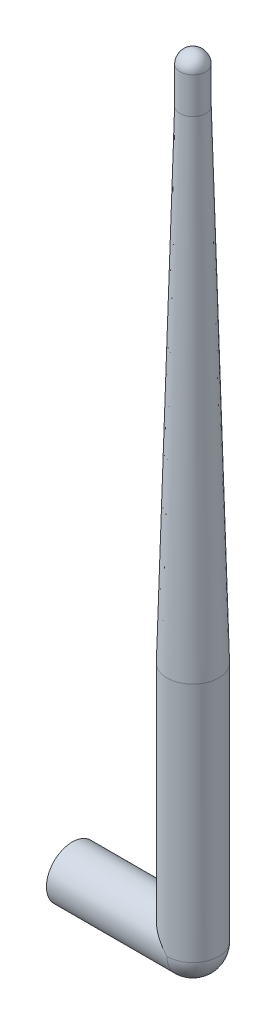
from build123d import *

# Parameters (mm, degrees)
SKETCH1_R           = 5.461
BOSS_EXTRUDE1_DEPTH = 25.4
SKETCH2_R           = 4.191
CUT_EXTRUDE1_DEPTH  = 7.62
SKETCH3_R           = 5.461
BOSS_EXTRUDE2_DEPTH = 50.8
REVOLVE2_ANGLE      = 90
SKETCH8_R           = 2.7305
SKETCH9_R           = 2.7305
BOSS_EXTRUDE3_DEPTH = 7.62
REVOLVE3_ANGLE      = 180


with BuildPart() as part:
    # Sketch1 → Boss-Extrude1 (new body)
    with BuildSketch(Plane(origin=(0, 0, 0), x_dir=(0, 0, -1), z_dir=(1, 0, 0))):
        Circle(SKETCH1_R)
    extrude(amount=BOSS_EXTRUDE1_DEPTH)

    # Sketch2 → Cut-Extrude1 (cut)
    with BuildSketch(Plane.ZY):
        Circle(SKETCH2_R)
    extrude(amount=-CUT_EXTRUDE1_DEPTH, mode=Mode.SUBTRACT)

    # Sketch3 → Boss-Extrude2 (add)
    with BuildSketch(Plane(origin=(0, 0, 0), x_dir=(1, 0, 0), z_dir=(0, 1, 0))):
        with Locations((25.4, 0)):
            Circle(SKETCH3_R)
    extrude(amount=BOSS_EXTRUDE2_DEPTH)

    # Sketch7 → Revolve2 (revolve)
    with BuildSketch(Plane(origin=(25.4, 0, 0), x_dir=(0, 0, -1), z_dir=(1, 0, 0))):
        with BuildLine():
            Line((5.461, 0), (-5.461, 0))
            ThreePointArc((-5.461, 0), (0, -5.461), (5.461, 0))
        make_face()
    revolve(axis=Axis((25.4, 0, -5.461), (0, 0, 1)), revolution_arc=REVOLVE2_ANGLE)

    # Sketch8 → section 1 of loft2
    with BuildSketch(Plane(origin=(0, 152.4, 0), x_dir=(1, 0, 0), z_dir=(0, 1, 0)), mode=Mode.PRIVATE) as loft2_s1:
        with Locations((25.4, 0)):
            Circle(SKETCH8_R)
    # loft from a face of the part (loft2)
    loft([part.faces().sort_by_distance((25.4, 50.8, 0))[0], loft2_s1.sketch])

    # Sketch9 → Boss-Extrude3 (add)
    with BuildSketch(Plane(origin=(0, 152.4, 0), x_dir=(1, 0, 0), z_dir=(0, 1, 0))):
        with Locations((25.4, 0)):
            Circle(SKETCH9_R)
    extrude(amount=BOSS_EXTRUDE3_DEPTH)

    # Sketch10 → Revolve3 (revolve)
    with BuildSketch(Plane(origin=(0, 160.02, 0), x_dir=(1, 0, 0), z_dir=(0, 1, 0))):
        with BuildLine():
            Line((25.4, 2.7305), (25.4, -2.7305))
            ThreePointArc((25.4, -2.7305), (28.1305, 0), (25.4, 2.7305))
        make_face()
    revolve(axis=Axis((25.4, 160.02, -2.7305), (0, 0, 1)), revolution_arc=REVOLVE3_ANGLE)


solid = part.part
